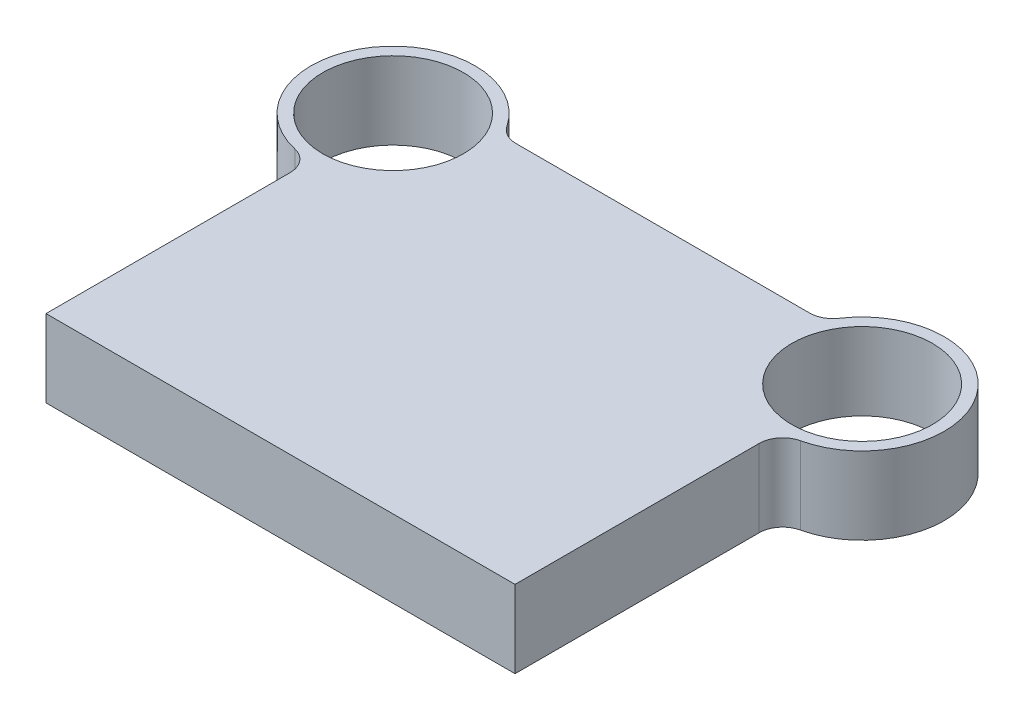
from build123d import *

# Parameters (mm, degrees)
SKETCH1_R           = 30
BOSS_EXTRUDE1_DEPTH = 33
FILLET1_R           = 10


with BuildPart() as part:
    # Sketch1 → Boss-Extrude1 (new body)
    with BuildSketch(Plane(origin=(0, 0, 0), x_dir=(1, 0, 0), z_dir=(0, 1, 0))):
        with BuildLine():
            Line((100, 0), (-100, 0))
            Line((-100, 0), (-100, 113))
            ThreePointArc((-100, 113), (-129.580398915, 166.708286934), (-68.377223398, 163))
            Line((-68.377223398, 163), (68.377223398, 163))
            ThreePointArc((68.377223398, 163), (129.580398915, 166.708286934), (100, 113))
            Line((100, 113), (100, 0))
        make_face()
        with Locations((-100, 148)):
            Circle(SKETCH1_R, mode=Mode.SUBTRACT)
        with Locations((100, 148)):
            Circle(SKETCH1_R, mode=Mode.SUBTRACT)
    extrude(amount=BOSS_EXTRUDE1_DEPTH)

    # Fillet1
    fillet1_edges = [part.edges().sort_by_distance(p)[0] for p in [
        (-100, 16.5, -113),
        (-68.377223398, 16.5, -163),
        (68.377223398, 16.5, -163),
        (100, 16.5, -113),
    ]]
    fillet(fillet1_edges, radius=FILLET1_R)


solid = part.part
